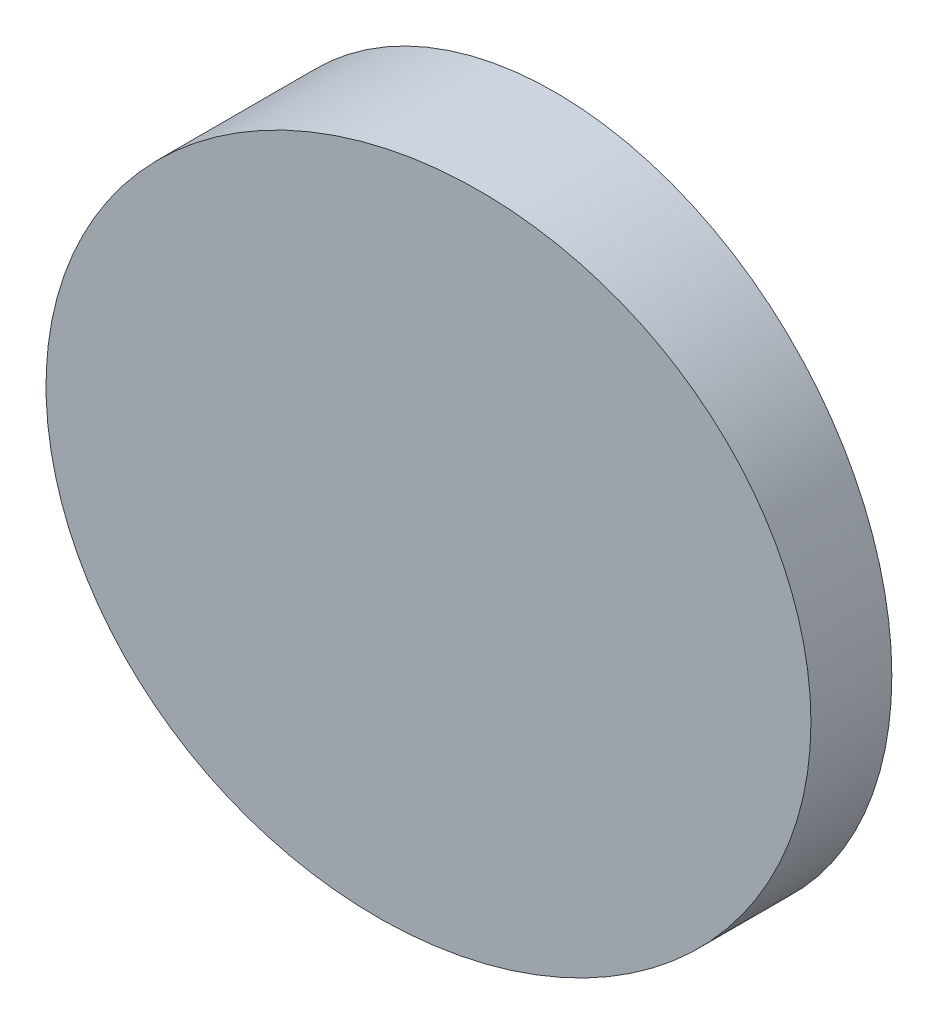
from build123d import *

# Parameters (mm, degrees)
SKETCH_1_R          = 12.5
EXTRUDE_1_DEPTH     = 10
CUT_EXTRUDE_1_DEPTH = 25


with BuildPart() as part:
    # 草图1 → 凸台-拉伸1 (new body)
    with BuildSketch(Plane.XY):
        Circle(SKETCH_1_R)
    extrude(amount=EXTRUDE_1_DEPTH)

    # 草图2 → 切除-拉伸1 (cut, symmetric)
    with BuildSketch(Plane(origin=(0, 0, 0), x_dir=(1, 0, 0), z_dir=(0, 1, 0))):
        Polygon((12.5, -3), (-16.380737105, -6.894563773), (-16.380737105, -17.832396763), (18.028093977, -17.832396763), (18.028093977, -3), align=None)
    extrude(amount=CUT_EXTRUDE_1_DEPTH, both=True, mode=Mode.SUBTRACT)


solid = part.part
